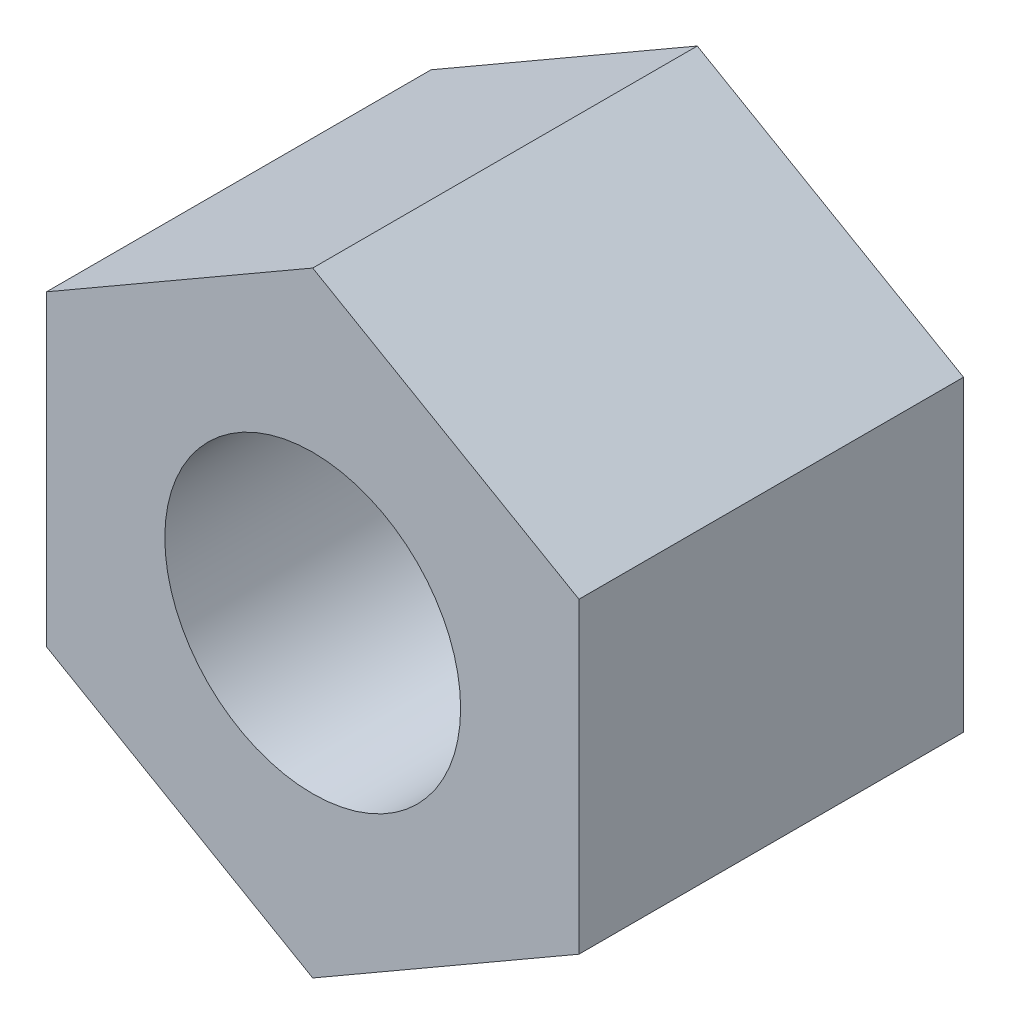
from build123d import *

# Parameters (mm, degrees)
SKETCH1_R           = 1.5
BOSS_EXTRUDE1_DEPTH = 3.9


with BuildPart() as part:
    # Sketch1 → Boss-Extrude1 (new body)
    with BuildSketch(Plane.XY):
        Polygon((0, 3.117691454), (-2.7, 1.558845727), (-2.7, -1.558845727), (0, -3.117691454), (2.7, -1.558845727), (2.7, 1.558845727), align=None)
        Circle(SKETCH1_R, mode=Mode.SUBTRACT)
    extrude(amount=BOSS_EXTRUDE1_DEPTH)


solid = part.part
